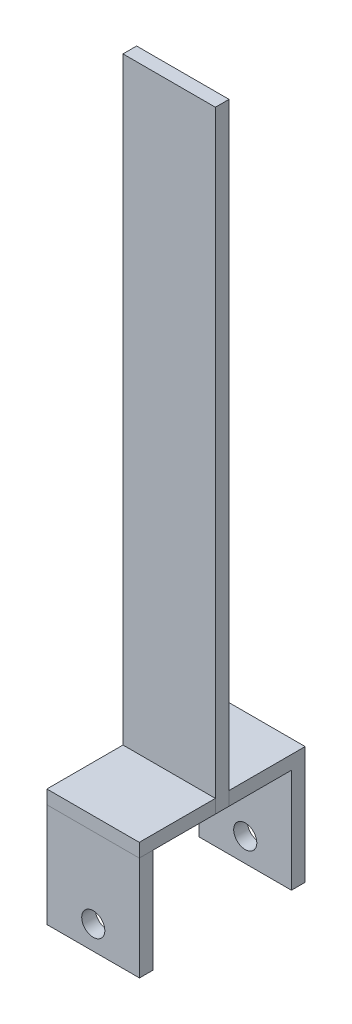
from build123d import *

# Parameters (mm, degrees)
SKETCH1_W           = 20.32
SKETCH1_H           = 134.62
BOSS_EXTRUDE1_DEPTH = 2.999994
BOSS_EXTRUDE2_DEPTH = 2.999994
BOSS_EXTRUDE3_DEPTH = 22.86
SKETCH4_R           = 2.54
CUT_EXTRUDE1_DEPTH  = 37.477194


with BuildPart() as part:
    # Sketch1 → Boss-Extrude1 (new body)
    with BuildSketch(Plane.XY):
        with Locations((-1.678928241, 0)):
            Rectangle(SKETCH1_W, SKETCH1_H)
    extrude(amount=BOSS_EXTRUDE1_DEPTH)

    # Sketch2 → Boss-Extrude2 (add)
    with BuildSketch(Plane(origin=(0, -67.31, 0), x_dir=(1, 0, 0), z_dir=(0, 1, 0))):
        Polygon((-11.838928241, 0), (-11.838928241, 16.7386), (8.478742997, 16.7386), (8.481071759, 0), (8.478742997, -2.999994), (8.481071759, -19.738594), (-11.838928241, -19.738594), (-11.838928241, -2.999994), align=None)
    extrude(amount=BOSS_EXTRUDE2_DEPTH)

    # Sketch3 → Boss-Extrude3 (add)
    with BuildSketch(Plane(origin=(0, -67.31, 0), x_dir=(-1, 0, 0), z_dir=(0, -1, 0))):
        Polygon((11.838928241, 16.7386), (11.838928241, 13.72362), (-8.479162457, 13.72362), (-8.478742997, 16.7386), align=None)
        Polygon((-8.481065309, -16.677248459), (-8.481065309, -19.692228459), (11.837025389, -19.692228459), (11.836605929, -16.677248459), align=None)
    extrude(amount=BOSS_EXTRUDE3_DEPTH)

    # Sketch4 → Cut-Extrude1 (cut, through all)
    with BuildSketch(Plane(origin=(0, 0, -16.7386), x_dir=(-1, 0, 0), z_dir=(0, 0, -1))):
        with Locations((1.680092622, -84.961272754)):
            Circle(SKETCH4_R)
    extrude(amount=-CUT_EXTRUDE1_DEPTH, mode=Mode.SUBTRACT)


solid = part.part
